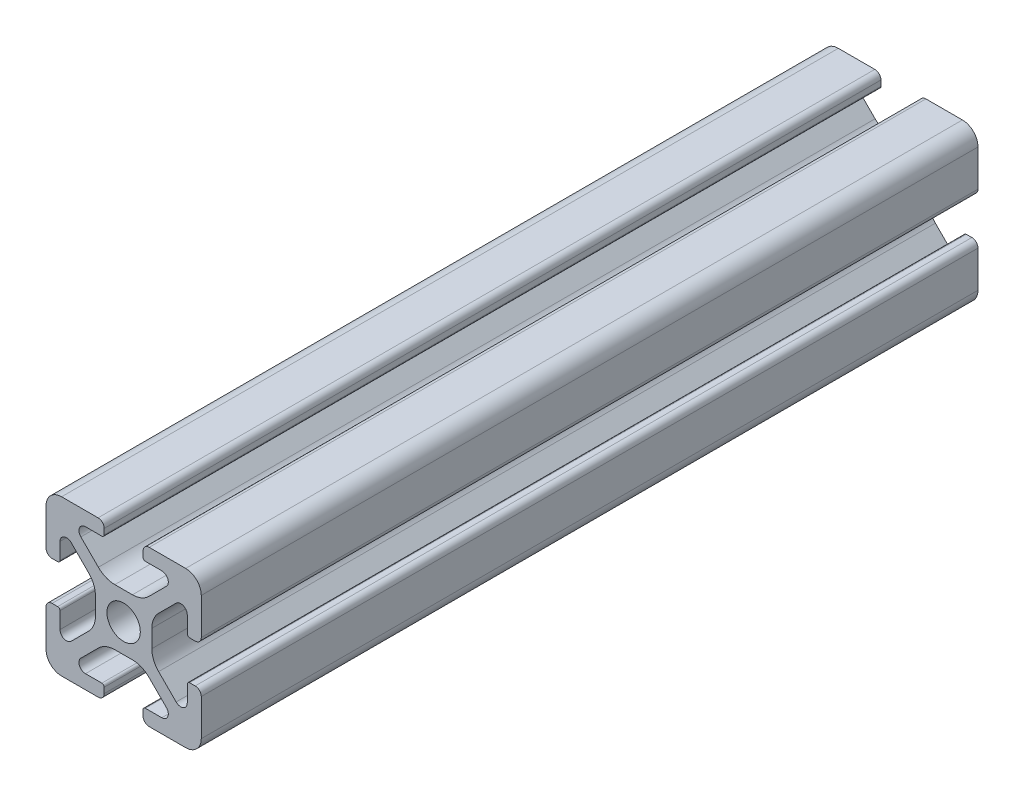
from build123d import *

# Parameters (mm, degrees)
SKETCH1_R           = 2.1463
BOSS_EXTRUDE1_DEPTH = 50


with BuildPart() as part:
    # Sketch1 → Boss-Extrude1 (new body, symmetric)
    with BuildSketch(Plane.XY):
        with BuildLine():
            Line((-9.9949, 7.9883), (-9.9949, 3.2893))
            ThreePointArc((-9.9949, 3.2893), (-9.76427588, 2.73252412), (-9.2075, 2.5019))
            Line((-9.2075, 2.5019), (-8.4963, 2.5019))
            ThreePointArc((-8.4963, 2.5019), (-8.280773853, 2.591173853), (-8.1915, 2.8067))
            Line((-8.1915, 2.8067), (-8.1915, 4.9149))
            ThreePointArc((-8.1915, 4.9149), (-7.674065253, 5.689295824), (-6.760603096, 5.507596904))
            Line((-6.760603096, 5.507596904), (-4.505765747, 3.252759555))
            ThreePointArc((-4.505765747, 3.252759555), (-3.856054457, 2.280397894), (-3.627906192, 1.133419111))
            Line((-3.627906192, 1.133419111), (-3.627906192, -1.133419111))
            ThreePointArc((-3.627906192, -1.133419111), (-3.856054457, -2.280397894), (-4.505765747, -3.252759555))
            Line((-4.505765747, -3.252759555), (-6.760603096, -5.507596904))
            ThreePointArc((-6.760603096, -5.507596904), (-7.674065253, -5.689295824), (-8.1915, -4.9149))
            Line((-8.1915, -4.9149), (-8.1915, -2.8067))
            ThreePointArc((-8.1915, -2.8067), (-8.280773853, -2.591173853), (-8.4963, -2.5019))
            Line((-8.4963, -2.5019), (-9.2075, -2.5019))
            ThreePointArc((-9.2075, -2.5019), (-9.76427588, -2.73252412), (-9.9949, -3.2893))
            Line((-9.9949, -3.2893), (-9.9949, -7.9883))
            ThreePointArc((-9.9949, -7.9883), (-9.407180467, -9.407180467), (-7.9883, -9.9949))
            Line((-7.9883, -9.9949), (-3.2893, -9.9949))
            ThreePointArc((-3.2893, -9.9949), (-2.73252412, -9.76427588), (-2.5019, -9.2075))
            Line((-2.5019, -9.2075), (-2.5019, -8.4963))
            ThreePointArc((-2.5019, -8.4963), (-2.591173853, -8.280773853), (-2.8067, -8.1915))
            Line((-2.8067, -8.1915), (-4.9149, -8.1915))
            ThreePointArc((-4.9149, -8.1915), (-5.689295824, -7.674065253), (-5.507596904, -6.760603096))
            Line((-5.507596904, -6.760603096), (-3.252759555, -4.505765747))
            ThreePointArc((-3.252759555, -4.505765747), (-2.280397894, -3.856054457), (-1.133419111, -3.627906192))
            Line((-1.133419111, -3.627906192), (1.133419111, -3.627906192))
            ThreePointArc((1.133419111, -3.627906192), (2.280397894, -3.856054457), (3.252759555, -4.505765747))
            Line((3.252759555, -4.505765747), (5.507596904, -6.760603096))
            ThreePointArc((5.507596904, -6.760603096), (5.689295824, -7.674065253), (4.9149, -8.1915))
            Line((4.9149, -8.1915), (2.8067, -8.1915))
            ThreePointArc((2.8067, -8.1915), (2.591173853, -8.280773853), (2.5019, -8.4963))
            Line((2.5019, -8.4963), (2.5019, -9.2075))
            ThreePointArc((2.5019, -9.2075), (2.73252412, -9.76427588), (3.2893, -9.9949))
            Line((3.2893, -9.9949), (7.9883, -9.9949))
            ThreePointArc((7.9883, -9.9949), (9.407180467, -9.407180467), (9.9949, -7.9883))
            Line((9.9949, -7.9883), (9.9949, -3.2893))
            ThreePointArc((9.9949, -3.2893), (9.76427588, -2.73252412), (9.2075, -2.5019))
            Line((9.2075, -2.5019), (8.4963, -2.5019))
            ThreePointArc((8.4963, -2.5019), (8.280773853, -2.591173853), (8.1915, -2.8067))
            Line((8.1915, -2.8067), (8.1915, -4.9149))
            ThreePointArc((8.1915, -4.9149), (7.674065253, -5.689295824), (6.760603096, -5.507596904))
            Line((6.760603096, -5.507596904), (4.505765747, -3.252759555))
            ThreePointArc((4.505765747, -3.252759555), (3.856054457, -2.280397894), (3.627906192, -1.133419111))
            Line((3.627906192, -1.133419111), (3.627906192, 1.133419111))
            ThreePointArc((3.627906192, 1.133419111), (3.856054457, 2.280397894), (4.505765747, 3.252759555))
            Line((4.505765747, 3.252759555), (6.760603096, 5.507596904))
            ThreePointArc((6.760603096, 5.507596904), (7.674065253, 5.689295824), (8.1915, 4.9149))
            Line((8.1915, 4.9149), (8.1915, 2.8067))
            ThreePointArc((8.1915, 2.8067), (8.280773853, 2.591173853), (8.4963, 2.5019))
            Line((8.4963, 2.5019), (9.2075, 2.5019))
            ThreePointArc((9.2075, 2.5019), (9.76427588, 2.73252412), (9.9949, 3.2893))
            Line((9.9949, 3.2893), (9.9949, 7.9883))
            ThreePointArc((9.9949, 7.9883), (9.407180467, 9.407180467), (7.9883, 9.9949))
            Line((7.9883, 9.9949), (3.2893, 9.9949))
            ThreePointArc((3.2893, 9.9949), (2.73252412, 9.76427588), (2.5019, 9.2075))
            Line((2.5019, 9.2075), (2.5019, 8.4963))
            ThreePointArc((2.5019, 8.4963), (2.591173853, 8.280773853), (2.8067, 8.1915))
            Line((2.8067, 8.1915), (4.9149, 8.1915))
            ThreePointArc((4.9149, 8.1915), (5.689295824, 7.674065253), (5.507596904, 6.760603096))
            Line((5.507596904, 6.760603096), (3.252759555, 4.505765747))
            ThreePointArc((3.252759555, 4.505765747), (2.280397894, 3.856054457), (1.133419111, 3.627906192))
            Line((1.133419111, 3.627906192), (-1.133419111, 3.627906192))
            ThreePointArc((-1.133419111, 3.627906192), (-2.280397894, 3.856054457), (-3.252759555, 4.505765747))
            Line((-3.252759555, 4.505765747), (-5.507596904, 6.760603096))
            ThreePointArc((-5.507596904, 6.760603096), (-5.689295824, 7.674065253), (-4.9149, 8.1915))
            Line((-4.9149, 8.1915), (-2.8067, 8.1915))
            ThreePointArc((-2.8067, 8.1915), (-2.591173853, 8.280773853), (-2.5019, 8.4963))
            Line((-2.5019, 8.4963), (-2.5019, 9.2075))
            ThreePointArc((-2.5019, 9.2075), (-2.73252412, 9.76427588), (-3.2893, 9.9949))
            Line((-3.2893, 9.9949), (-7.9883, 9.9949))
            ThreePointArc((-7.9883, 9.9949), (-9.407180467, 9.407180467), (-9.9949, 7.9883))
        make_face()
        Circle(SKETCH1_R, mode=Mode.SUBTRACT)
    extrude(amount=BOSS_EXTRUDE1_DEPTH, both=True)


solid = part.part
